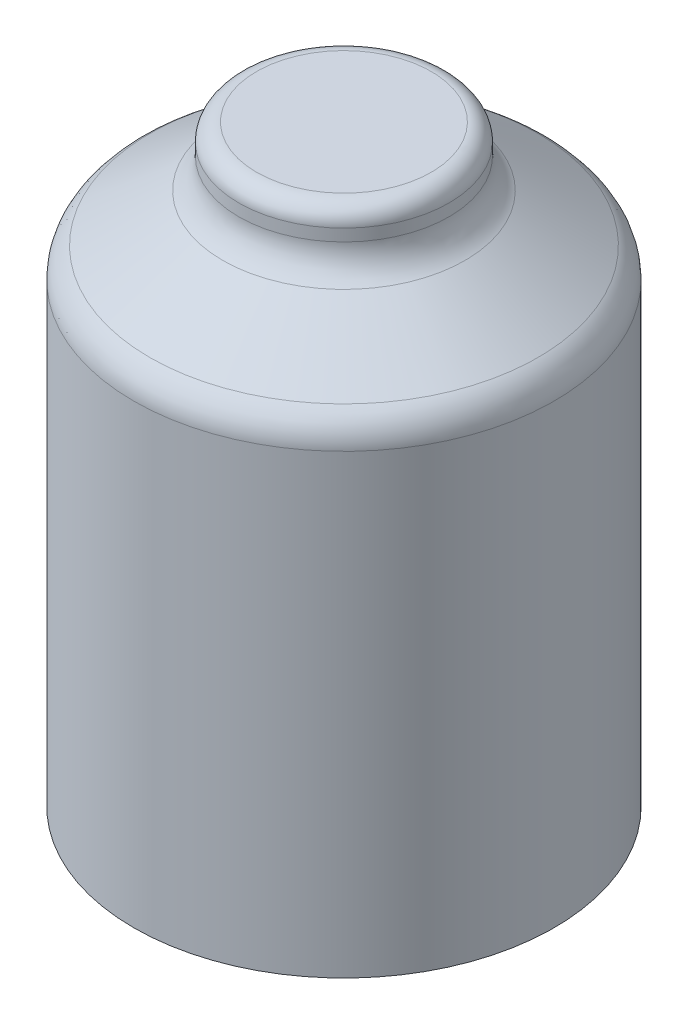
from build123d import *


with BuildPart() as part:
    # Sketch1 → Revolve1 (revolve)
    with BuildSketch(Plane.XY):
        with BuildLine():
            Line((0, 0), (0, -33.42037452))
            Line((0, -33.42037452), (11.846734569, -33.42037452))
            Line((11.846734569, -33.42037452), (11.846734569, -7.708743439))
            ThreePointArc((11.846734569, -7.708743439), (11.605583733, -6.75666696), (10.940284949, -6.034184521))
            Line((10.940284949, -6.034184521), (6.829816905, -3.349893247))
            ThreePointArc((6.829816905, -3.349893247), (6.164518121, -2.627410808), (5.923367285, -1.67533433))
            Line((5.923367285, -1.67533433), (5.923367285, -1))
            ThreePointArc((5.923367285, -1), (5.630474066, -0.292893219), (4.923367285, 0))
            Line((4.923367285, 0), (0, 0))
        make_face()
    revolve(axis=Axis((0, 0, 0), (0, -1, 0)))


solid = part.part
